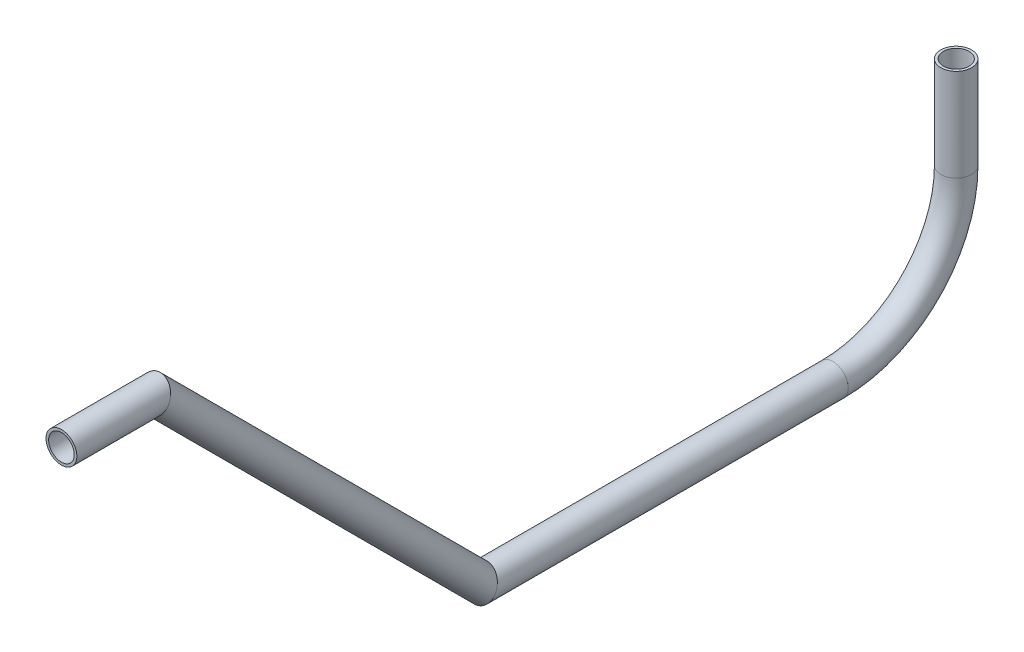
from build123d import *

# Parameters (mm, degrees)
SKETCH11_R                = 6.35
SKETCH11_R_2              = 5.2832
PIPE_0_5_SCH_40_1_DEPTH   = 42.819743879
SKETCH11_ON_SEGMENT_2_R   = 6.35
SKETCH11_ON_SEGMENT_2_R_2 = 5.2832
PIPE_0_5_SCH_40_1_2_DEPTH = 199.75069677
SKETCH11_ON_SEGMENT_3_R   = 6.35
SKETCH11_ON_SEGMENT_3_R_2 = 5.2832
PIPE_0_5_SCH_40_1_3_DEPTH = 149.762254009
SKETCH11_ON_SEGMENT_4_R   = 6.35
SKETCH11_ON_SEGMENT_4_R_2 = 5.2832
PIPE_0_5_SCH_40_1_4_ANGLE = 90
SKETCH11_ON_SEGMENT_5_R   = 6.35
SKETCH11_ON_SEGMENT_5_R_2 = 5.2832
PIPE_0_5_SCH_40_1_5_DEPTH = 38.1


with BuildPart() as part:
    # Sketch11 → Pipe 0.5 SCH 40(1) (new body)
    with BuildSketch(Plane(origin=(0, 599.763297601, 303.593044312), x_dir=(0, 1, 0), z_dir=(0, 0, -1))):
        Circle(SKETCH11_R)
        Circle(SKETCH11_R_2, mode=Mode.SUBTRACT)
    extrude(amount=PIPE_0_5_SCH_40_1_DEPTH)

    # Pipe 0.5 SCH 40(1) mitre 1
    split(bisect_by=Plane(origin=(0, 599.763297601, 265.493044312), x_dir=(0, -0.923879533, 0.382683432), z_dir=(0, 0.382683432, 0.923879533)), keep=Keep.TOP)


with BuildPart() as body_2:
    # Sketch11 on segment 2 (carried to segment 2) → Pipe 0.5 SCH 40_1 2 (new body)
    with BuildSketch(Plane(origin=(0, 603.100660503, 268.830407214), x_dir=(0, 0.707106781, -0.707106781), z_dir=(0, -0.707106781, -0.707106781))):
        Circle(SKETCH11_ON_SEGMENT_2_R)
        Circle(SKETCH11_ON_SEGMENT_2_R_2, mode=Mode.SUBTRACT)
    extrude(amount=PIPE_0_5_SCH_40_1_2_DEPTH)

    # Pipe 0.5 SCH 40_1 2 mitre 1
    split(bisect_by=Plane(origin=(0, 599.763297601, 265.493044312), x_dir=(0, 0.923879533, -0.382683432), z_dir=(0, -0.382683432, -0.923879533)), keep=Keep.TOP)

    # Pipe 0.5 SCH 40_1 2 mitre 2
    split(bisect_by=Plane(origin=(0, 465.192951173, 130.922697884), x_dir=(0, -0.923879533, 0.382683432), z_dir=(0, 0.382683432, 0.923879533)), keep=Keep.TOP)


with BuildPart() as body_3:
    # Sketch11 on segment 3 (carried to segment 3) → Pipe 0.5 SCH 40_1 3 (new body)
    with BuildSketch(Plane(origin=(0, 465.192951173, 135.642441763), x_dir=(0, 1, 0), z_dir=(0, 0, -1))):
        Circle(SKETCH11_ON_SEGMENT_3_R)
        Circle(SKETCH11_ON_SEGMENT_3_R_2, mode=Mode.SUBTRACT)
    extrude(amount=PIPE_0_5_SCH_40_1_3_DEPTH)

    # Pipe 0.5 SCH 40_1 3 mitre 1
    split(bisect_by=Plane(origin=(0, 465.192951173, 130.922697884), x_dir=(0, 0.923879533, -0.382683432), z_dir=(0, -0.382683432, -0.923879533)), keep=Keep.TOP)


with BuildPart() as body_4:
    # Sketch11 on segment 4 (carried to the start of arc 4) → Pipe 0.5 SCH 40_1 4 (revolve)
    with BuildSketch(Plane(origin=(0, 465.192951173, -14.119812247), x_dir=(0, 1, 0), z_dir=(0, 0, -1))):
        Circle(SKETCH11_ON_SEGMENT_4_R)
        Circle(SKETCH11_ON_SEGMENT_4_R_2, mode=Mode.SUBTRACT)
    revolve(axis=Axis((0, 515.992951173, -14.119812247), (1, 0, 0)), revolution_arc=PIPE_0_5_SCH_40_1_4_ANGLE)


with BuildPart() as body_5:
    # Sketch11 on segment 5 (carried to segment 5) → Pipe 0.5 SCH 40_1 5 (new body)
    with BuildSketch(Plane(origin=(0, 554.092951173, -64.919812247), x_dir=(0, 0, -1), z_dir=(0, -1, 0))):
        Circle(SKETCH11_ON_SEGMENT_5_R)
        Circle(SKETCH11_ON_SEGMENT_5_R_2, mode=Mode.SUBTRACT)
    extrude(amount=PIPE_0_5_SCH_40_1_5_DEPTH)


solid = Compound([part.part, body_2.part, body_3.part, body_4.part, body_5.part])
